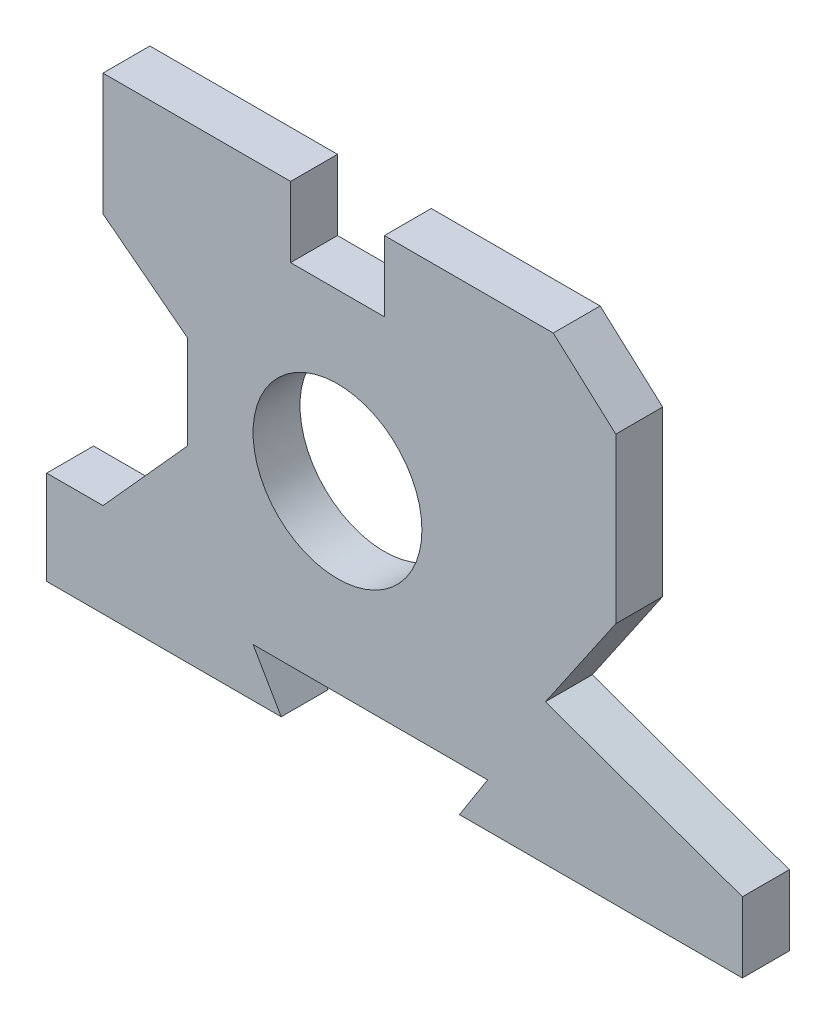
from build123d import *

# Parameters (mm, degrees)
SKETCH1_R           = 18
BOSS_EXTRUDE2_DEPTH = 10


with BuildPart() as part:
    # Sketch1 → Boss-Extrude2 (new body)
    with BuildSketch(Plane.XY):
        Polygon((17.423284477, -47.225403837), (77.753284477, -47.225403837), (77.753284477, -32.225403837), (35.753284477, -17.225403837), (50.753284477, 4.694596163), (50.753284477, 39.694596163), (37.423284477, 51.694596163), (1.423284477, 51.694596163), (1.423284477, 36.694596163), (-18.576715523, 36.694596163), (-18.576715523, 51.694596163), (-58.576715523, 51.694596163), (-58.576715523, 25.694596163), (-40.576715523, 11.834793389), (-40.576715523, -8.165206611), (-58.576715523, -28.165206611), (-70.576715523, -28.165206611), (-70.576715523, -48.165206611), (-20.576715523, -48.165206611), (-26.576715523, -37.805403837), (23.423284477, -37.805403837), align=None)
        with Locations((-8.576715523, 1.334793389)):
            Circle(SKETCH1_R, mode=Mode.SUBTRACT)
    extrude(amount=BOSS_EXTRUDE2_DEPTH)


solid = part.part
